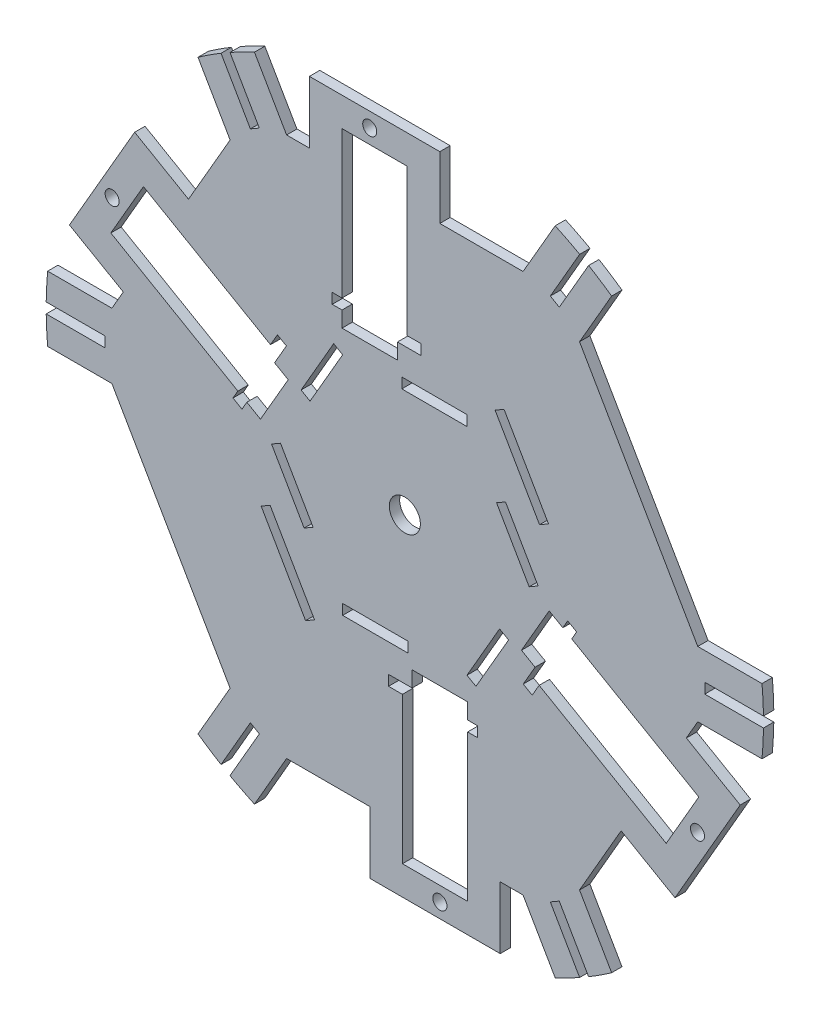
from build123d import *

# Parameters (mm, degrees)
SKETCH1_R                   = 110
SKETCH1_R_2                 = 4.7625
BOSS_EXTRUDE1_DEPTH         = 1.5875
SKETCH2_R                   = 2.15375
CUT_EXTRUDE3_DEPTH          = 4.175
CIRPATTERN1_COUNT           = 2
CIRPATTERN2_COUNT           = 2
CIRPATTERN2_ANGLE           = 60
CIRPATTERN2_COPY_1_SKETCH_R = 2.15375
CIRPATTERN2_COPY_1_DEPTH    = 4.175
CUT_EXTRUDE5_DEPTH          = 4.175
CUT_EXTRUDE8_DEPTH          = 5
SKETCH11_W                  = 27.2625
SKETCH11_H                  = 3.175
SKETCH11_W_2                = 20
CUT_EXTRUDE24_DEPTH         = 5


with BuildPart() as part:
    # Sketch1 → Boss-Extrude1 (new body, symmetric)
    with BuildSketch(Plane.XY):
        Circle(SKETCH1_R)
        Circle(SKETCH1_R_2, mode=Mode.SUBTRACT)
        Polygon((-4.7625, 40), (-2.2625, 40), (-2.2625, 48), (0.7375, 48), (0.7375, 93), (-19.2625, 93), (-19.2625, 40), (-16.7625, 40), align=None, mode=Mode.SUBTRACT)
        Polygon((4.7625, -40), (2.2625, -40), (2.2625, -48), (-0.7375, -48), (-0.7375, -93), (19.2625, -93), (19.2625, -40), (16.7625, -40), align=None, mode=Mode.SUBTRACT)
        Polygon((37.022266151, -15.875554014), (35.772266151, -18.040617524), (42.700469382, -22.040617524), (41.200469382, -24.638693735), (80.171612552, -47.138693735), (90.171612552, -29.81818566), (44.272266151, -3.31818566), (43.022266151, -5.483249169), align=None, mode=Mode.SUBTRACT)
        Polygon((-37.022266151, 15.875554014), (-35.772266151, 18.040617524), (-42.700469382, 22.040617524), (-41.200469382, 24.638693735), (-80.171612552, 47.138693735), (-90.171612552, 29.81818566), (-44.272266151, 3.31818566), (-43.022266151, 5.483249169), align=None, mode=Mode.SUBTRACT)
    extrude(amount=BOSS_EXTRUDE1_DEPTH, both=True)

    # Sketch2 → Cut-Extrude3 (cut, through all)
    with BuildSketch(Plane.XY.offset(1.5875)):
        with Locations((10.7625, -97.43875)):
            Circle(SKETCH2_R)
        with BuildLine():
            Line((-10.7375, -82.808492409), (-10.7375, -101.88))
            Line((-10.7375, -101.88), (9.2625, -101.88))
            Line((9.2625, -101.88), (29.2625, -101.88))
            Line((29.2625, -101.88), (29.2625, -82.808492409))
            Line((29.2625, -82.808492409), (36.2625, -82.808492409))
            Line((36.2625, -82.808492409), (46.112001713, -99.868329805))
            ThreePointArc((46.112001713, -99.868329805), (0, -110), (-46.112001713, -99.868329805))
            Line((-46.112001713, -99.868329805), (-36.2625, -82.808492409))
            Line((-36.2625, -82.808492409), (-10.7375, -82.808492409))
        make_face()
    cut_extrude3 = extrude(amount=-CUT_EXTRUDE3_DEPTH, mode=Mode.SUBTRACT)

    # CirPattern1: Cut-Extrude3 ×2 about axis
    cirpattern1_axis = Axis((0, 0, 0), (0, 0, 1))
    for i in range(1, CIRPATTERN1_COUNT):
        add(cut_extrude3.rotate(cirpattern1_axis, i * 360 / CIRPATTERN1_COUNT), mode=Mode.SUBTRACT)

    # CirPattern2: Cut-Extrude3 ×2 about axis
    cirpattern2_axis = Axis((0, 0, 0), (0, 0, 1))
    for i in range(1, CIRPATTERN2_COUNT):
        add(cut_extrude3.rotate(cirpattern2_axis, i * CIRPATTERN2_ANGLE / (CIRPATTERN2_COUNT - 1)), mode=Mode.SUBTRACT)

    # CirPattern2 copy 1 sketch → CirPattern2 copy 1 (cut, through all)
    with BuildSketch(Plane(origin=(0, 0, 1.5875), x_dir=(-0.5, -0.866025404, 0), z_dir=(0, 0, 1))):
        with Locations((10.7625, -97.43875)):
            Circle(CIRPATTERN2_COPY_1_SKETCH_R)
        with BuildLine():
            Line((-10.7375, -82.808492409), (-10.7375, -101.88))
            Line((-10.7375, -101.88), (9.2625, -101.88))
            Line((9.2625, -101.88), (29.2625, -101.88))
            Line((29.2625, -101.88), (29.2625, -82.808492409))
            Line((29.2625, -82.808492409), (36.2625, -82.808492409))
            Line((36.2625, -82.808492409), (46.112001713, -99.868329805))
            ThreePointArc((46.112001713, -99.868329805), (0, -110), (-46.112001713, -99.868329805))
            Line((-46.112001713, -99.868329805), (-36.2625, -82.808492409))
            Line((-36.2625, -82.808492409), (-10.7375, -82.808492409))
        make_face()
    extrude(amount=-CIRPATTERN2_COPY_1_DEPTH, mode=Mode.SUBTRACT)

    # Sketch5 → Cut-Extrude5 (cut, through all)
    with BuildSketch(Plane.XY.offset(1.5875)):
        with BuildLine():
            Line((89.845508076, 10), (53.583008076, 72.808492409))
            Line((53.583008076, 72.808492409), (63.432509788, 89.868329805))
            ThreePointArc((63.432509788, 89.868329805), (95.262794416, 55), (109.544511501, 10))
            Line((109.544511501, 10), (89.845508076, 10))
        make_face()
        with BuildLine():
            Line((-89.845508076, -10), (-53.583008076, -72.808492409))
            Line((-53.583008076, -72.808492409), (-63.432509788, -89.868329805))
            ThreePointArc((-63.432509788, -89.868329805), (-95.262794416, -55), (-109.544511501, -10))
            Line((-109.544511501, -10), (-89.845508076, -10))
        make_face()
    extrude(amount=-CUT_EXTRUDE5_DEPTH, mode=Mode.SUBTRACT)

    # Sketch10 → Cut-Extrude8 (cut, symmetric)
    with BuildSketch(Plane.XY.offset(1.5875)):
        Polygon((-65.369087402, -110.047580625), (-56.369087402, -94.459123357), (-47.369087402, -78.870666089), (-44.619456745, -80.458166089), (-53.619456745, -96.046623357), (-62.619456745, -111.635080625), align=None)
        Polygon((-127.988544148, 1.5875), (-109.988544148, 1.5875), (-91.988544148, 1.5875), (-91.988544148, -1.5875), (-109.988544148, -1.5875), (-127.988544148, -1.5875), align=None)
        Polygon((-62.619456745, 111.635080625), (-53.619456745, 96.046623357), (-44.619456745, 80.458166089), (-47.369087402, 78.870666089), (-56.369087402, 94.459123357), (-65.369087402, 110.047580625), align=None)
        Polygon((65.369087402, 110.047580625), (56.369087402, 94.459123357), (47.369087402, 78.870666089), (44.619456745, 80.458166089), (53.619456745, 96.046623357), (62.619456745, 111.635080625), align=None)
        Polygon((127.988544148, -1.5875), (109.988544148, -1.5875), (91.988544148, -1.5875), (91.988544148, 1.5875), (109.988544148, 1.5875), (127.988544148, 1.5875), align=None)
        Polygon((62.619456745, -111.635080625), (53.619456745, -96.046623357), (44.619456745, -80.458166089), (47.369087402, -78.870666089), (56.369087402, -94.459123357), (65.369087402, -110.047580625), align=None)
    extrude(amount=CUT_EXTRUDE8_DEPTH, both=True, mode=Mode.SUBTRACT)

    # Sketch11 → Cut-Extrude24 (cut, symmetric)
    with BuildSketch(Plane.XY.offset(1.5875)):
        with Locations((8.63125, -46.4125)):
            Rectangle(SKETCH11_W, SKETCH11_H)
        Polygon((-44.069219382, -19.669872981), (-30.437969382, -43.279890552), (-27.688338725, -41.692390552), (-41.319588725, -18.082372981), align=None)
        with Locations((-9.06699264, -34.6125)):
            Rectangle(SKETCH11_W_2, SKETCH11_H)
        Polygon((-38.13398528, 0), (-40.883615937, -1.5875), (-30.883615937, -18.908008076), (-28.13398528, -17.320508076), align=None)
        Polygon((-39.069219382, 28.330127019), (-52.700469382, 4.720109448), (-49.950838725, 3.132609448), (-36.319588725, 26.742627019), align=None)
        Polygon((-19.06699264, 33.025), (-21.816623297, 34.6125), (-31.816623297, 17.291991924), (-29.06699264, 15.704491924), align=None)
        with Locations((-8.63125, 46.4125)):
            Rectangle(SKETCH11_W, SKETCH11_H)
        with Locations((9.06699264, 34.6125)):
            Rectangle(SKETCH11_W_2, SKETCH11_H)
        Polygon((44.069219382, 19.669872981), (30.437969382, 43.279890552), (27.688338725, 41.692390552), (41.319588725, 18.082372981), align=None)
        Polygon((38.13398528, 0), (40.883615937, 1.5875), (30.883615937, 18.908008076), (28.13398528, 17.320508076), align=None)
        Polygon((39.069219382, -28.330127019), (52.700469382, -4.720109448), (49.950838725, -3.132609448), (36.319588725, -26.742627019), align=None)
        Polygon((19.06699264, -33.025), (21.816623297, -34.6125), (31.816623297, -17.291991924), (29.06699264, -15.704491924), align=None)
    extrude(amount=CUT_EXTRUDE24_DEPTH, both=True, mode=Mode.SUBTRACT)


solid = part.part
